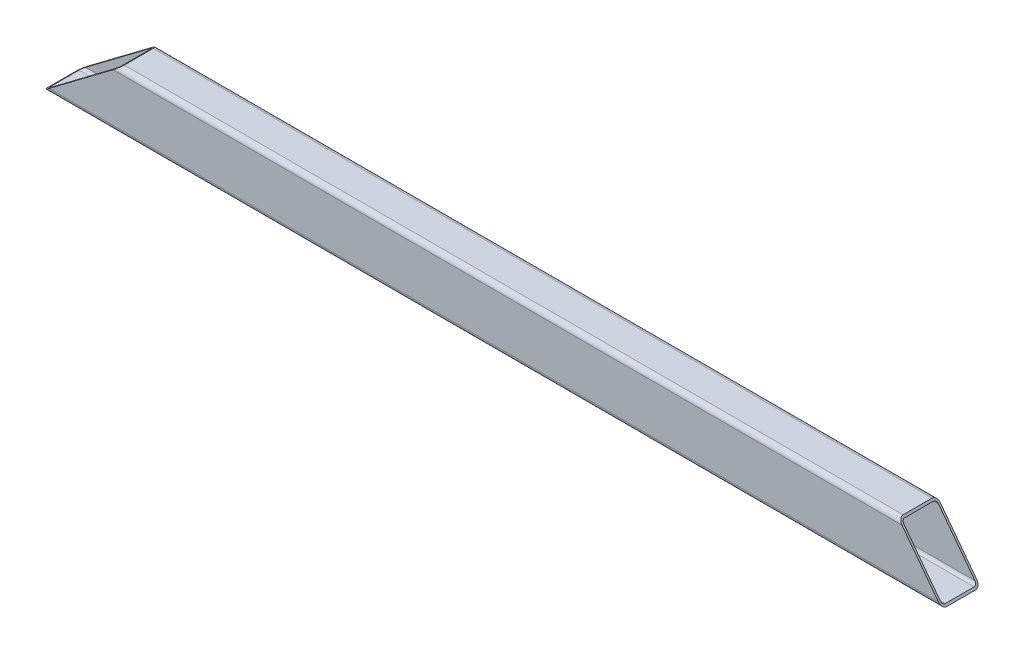
from build123d import *

# Parameters (mm, degrees)
EL_MENT_M_CANO_SOUD_1_DEPTH = 1883.6164
EXTRUSION1_DEPTH            = 81
EXTRUSION2_DEPTH            = 81


with BuildPart() as part:
    # Esquisse15 → Elément mécano-soudé1 (new body)
    with BuildSketch(Plane.YZ.offset(-941.8082)):
        with BuildLine():
            Line((-50, 40), (50, 40))
            ThreePointArc((50, 40), (57.071067812, 37.071067812), (60, 30))
            Line((60, 30), (60, -30))
            ThreePointArc((60, -30), (57.071067812, -37.071067812), (50, -40))
            Line((50, -40), (-50, -40))
            ThreePointArc((-50, -40), (-57.071067812, -37.071067812), (-60, -30))
            Line((-60, -30), (-60, 30))
            ThreePointArc((-60, 30), (-57.071067812, 37.071067812), (-50, 40))
        make_face()
        with BuildLine():
            Line((-50, 36), (50, 36))
            ThreePointArc((50, 36), (54.242640687, 34.242640687), (56, 30))
            Line((56, 30), (56, -30))
            ThreePointArc((56, -30), (54.242640687, -34.242640687), (50, -36))
            Line((50, -36), (-50, -36))
            ThreePointArc((-50, -36), (-54.242640687, -34.242640687), (-56, -30))
            Line((-56, -30), (-56, 30))
            ThreePointArc((-56, 30), (-54.242640687, 34.242640687), (-50, 36))
        make_face(mode=Mode.SUBTRACT)
    extrude(amount=EL_MENT_M_CANO_SOUD_1_DEPTH)

    # Esquisse12 → Extrusion1 (cut, through all)
    with BuildSketch(Plane.XY.offset(40)):
        Polygon((941.8082, -60), (851.381713988, 60), (941.8082, 60), align=None)
        Polygon((-941.8082, -60), (-782.562821406, 60), (-941.8082, 60), align=None)
    extrude(amount=-EXTRUSION1_DEPTH, mode=Mode.SUBTRACT)

    # Esquisse13 → Extrusion2 (cut, through all)
    with BuildSketch(Plane.XY.offset(40)):
        Polygon((-1042.175315796, -60), (-925.191798589, -60), (-765.946419994, 60), (-882.929937201, 60), align=None)
    extrude(amount=-EXTRUSION2_DEPTH, mode=Mode.SUBTRACT)


solid = part.part
